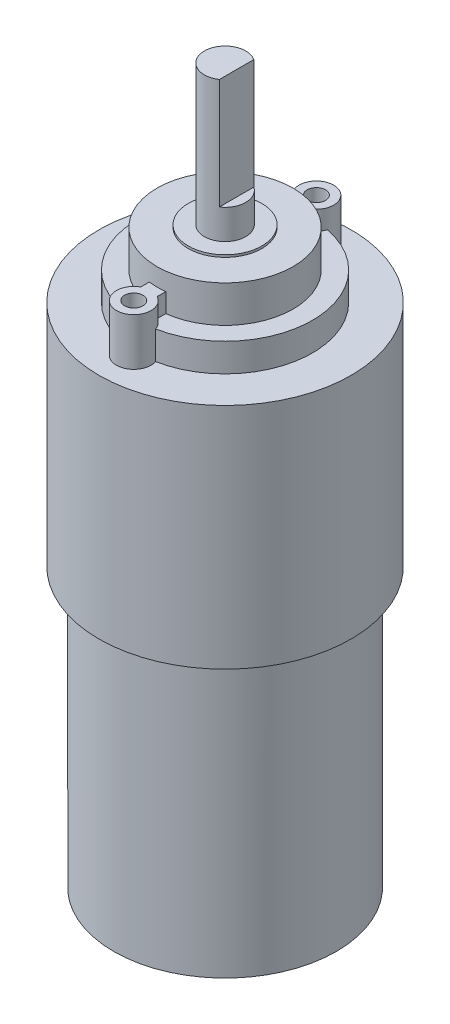
from build123d import *

# Parameters (mm, degrees)
FRONT_CYLINDER_SKETCH_R    = 13.7
FRONT_CYLINDER_DEPTH       = 24.81270946
MOUNTING_POINT_SKETCH_R    = 1
MOUNTING_POINTS_DEPTH      = 5.15
GEAR_MOUNT_BOTTOM_SKETCH_R = 9.5
GEAR_MOUNT_BOTTOM_DEPTH    = 3.074685726
GEAR_MOUNT_TOP_DEPTH       = 4
MOUNTING_HOLES_REACH       = 9.075
MOUNTING_HOLES_SKETCH_R    = 1
GEAR_DISK_SKETCH_R         = 4
GEAR_DISK_DEPTH            = 0.25
GEAR_SKETCH_R              = 2.25
GEAR_DEPTH                 = 15.225
GEAR_NOTCH_DEPTH           = 12
BACK_CYLINDER_SKETCH_R     = 12.1
BOSS_EXTRUDE7_DEPTH        = 30.2


with BuildPart() as part:
    # Front cylinder sketch → Front Cylinder (new body)
    with BuildSketch(Plane(origin=(0, 0, 0), x_dir=(1, 0, 0), z_dir=(0, 1, 0))):
        with Locations((10.070944868, -22.415974061)):
            Circle(FRONT_CYLINDER_SKETCH_R)
    extrude(amount=FRONT_CYLINDER_DEPTH)

    # Mounting Point Sketch → Mounting Points (add)
    with BuildSketch(Plane(origin=(0, 24.81270946, 0), x_dir=(1, 0, 0), z_dir=(0, 1, 0))):
        with BuildLine():
            Line((10.970944868, -15.079824378), (10.970944868, -14.148518185))
            ThreePointArc((10.970944868, -14.148518185), (10.070944868, -10.614245578), (9.170944868, -14.148518185))
            Line((9.170944868, -14.148518185), (9.170944868, -15.079824378))
            ThreePointArc((9.170944868, -15.079824378), (10.070944868, -15.024824478), (10.970944868, -15.079824378))
        make_face()
        with Locations((10.070944868, -12.495974061)):
            Circle(MOUNTING_POINT_SKETCH_R, mode=Mode.SUBTRACT)
        with BuildLine():
            Line((9.170944868, -29.752123743), (9.170944868, -30.683429936))
            ThreePointArc((9.170944868, -30.683429936), (10.070944868, -34.217702543), (10.970944868, -30.683429936))
            Line((10.970944868, -30.683429936), (10.970944868, -29.752123743))
            ThreePointArc((10.970944868, -29.752123743), (10.070944868, -29.807123644), (9.170944868, -29.752123743))
        make_face()
        with Locations((10.070944868, -32.335974061)):
            Circle(MOUNTING_POINT_SKETCH_R, mode=Mode.SUBTRACT)
    extrude(amount=MOUNTING_POINTS_DEPTH)

    # Gear Mount Bottom Sketch → Gear Mount Bottom (add)
    with BuildSketch(Plane(origin=(0, 24.81270946, 0), x_dir=(1, 0, 0), z_dir=(0, 1, 0))):
        with Locations((10.070944868, -22.415974061)):
            Circle(GEAR_MOUNT_BOTTOM_SKETCH_R)
    extrude(amount=GEAR_MOUNT_BOTTOM_DEPTH)

    # Gear Mount Top Sketch → Gear Mount Top (add)
    with BuildSketch(Plane(origin=(0, 27.887395186, 0), x_dir=(1, 0, 0), z_dir=(0, 1, 0))):
        with BuildLine():
            ThreePointArc((17.462094451, -22.415974061), (15.606336759, -17.518165493), (10.970944868, -15.079824378))
            ThreePointArc((10.970944868, -15.079824378), (10.070944868, -15.024824478), (9.170944868, -15.079824378))
            ThreePointArc((9.170944868, -15.079824378), (2.679795285, -22.415974061), (9.170944868, -29.752123743))
            ThreePointArc((9.170944868, -29.752123743), (10.070944868, -29.807123644), (10.970944868, -29.752123743))
            ThreePointArc((10.970944868, -29.752123743), (15.606336759, -27.313782629), (17.462094451, -22.415974061))
        make_face()
    extrude(amount=GEAR_MOUNT_TOP_DEPTH)

    # Mounting Holes Sketch → Mounting Holes (cut, up to next)
    with BuildSketch(Plane(origin=(0, 24.81270946, 0), x_dir=(1, 0, 0), z_dir=(0, 1, 0)), mode=Mode.PRIVATE) as mounting_holes_sk1:
        with Locations((10.070944868, -12.495974061)):
            Circle(MOUNTING_HOLES_SKETCH_R)
    mounting_holes_tool1 = extrude(mounting_holes_sk1.sketch, amount=MOUNTING_HOLES_REACH, mode=Mode.PRIVATE) & part.part
    add(mounting_holes_tool1.solids().sort_by_distance((10.070945, 24.812709, 12.495974))[0], mode=Mode.SUBTRACT)
    # Mounting Holes Sketch → Mounting Holes (cut, up to next)
    with BuildSketch(Plane(origin=(0, 24.81270946, 0), x_dir=(1, 0, 0), z_dir=(0, 1, 0)), mode=Mode.PRIVATE) as mounting_holes_sk2:
        with Locations((10.070944868, -32.335974061)):
            Circle(MOUNTING_HOLES_SKETCH_R)
    mounting_holes_tool2 = extrude(mounting_holes_sk2.sketch, amount=MOUNTING_HOLES_REACH, mode=Mode.PRIVATE) & part.part
    add(mounting_holes_tool2.solids().sort_by_distance((10.070945, 24.812709, 32.335974))[0], mode=Mode.SUBTRACT)

    # Gear Disk Sketch → Gear disk (add)
    with BuildSketch(Plane(origin=(0, 31.887395186, 0), x_dir=(1, 0, 0), z_dir=(0, 1, 0))):
        with Locations((10.070944868, -22.415974061)):
            Circle(GEAR_DISK_SKETCH_R)
    extrude(amount=GEAR_DISK_DEPTH)

    # Gear Sketch → Gear (add)
    with BuildSketch(Plane(origin=(0, 32.137395186, 0), x_dir=(1, 0, 0), z_dir=(0, 1, 0))):
        with Locations((10.070944868, -22.415974061)):
            Circle(GEAR_SKETCH_R)
    extrude(amount=GEAR_DEPTH)

    # Gear Notch Sketch → Gear Notch (cut)
    with BuildSketch(Plane(origin=(0, 47.362395186, 0), x_dir=(1, 0, 0), z_dir=(0, 1, 0))):
        with BuildLine():
            ThreePointArc((12.320944868, -22.415974061), (12.055258351, -21.355313889), (11.320944868, -20.545145367))
            Line((11.320944868, -20.545145367), (11.320944868, -24.286802754))
            ThreePointArc((11.320944868, -24.286802754), (12.055258351, -23.476634232), (12.320944868, -22.415974061))
        make_face()
    extrude(amount=-GEAR_NOTCH_DEPTH, mode=Mode.SUBTRACT)

    # Back Cylinder Sketch → Boss-Extrude7 (add)
    with BuildSketch(Plane.XZ):
        with Locations((10.070944868, 22.415974061)):
            Circle(BACK_CYLINDER_SKETCH_R)
    extrude(amount=BOSS_EXTRUDE7_DEPTH)


solid = part.part
